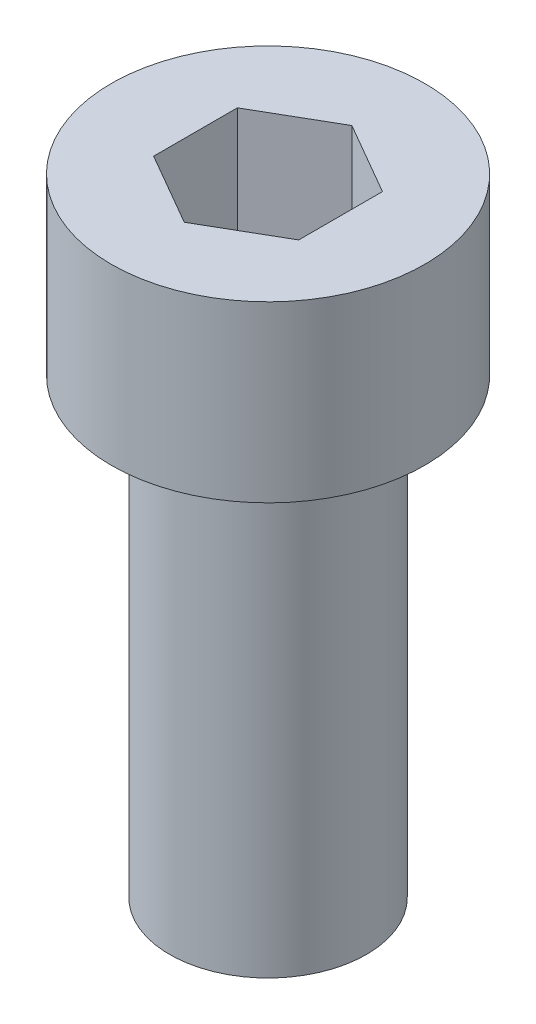
from build123d import *

# Parameters (mm, degrees)
SKETCH1_R           = 2.7
BOSS_EXTRUDE1_DEPTH = 3
SKETCH2_R           = 1.696293742
BOSS_EXTRUDE2_DEPTH = 7.8
CUT_EXTRUDE1_DEPTH  = 2


with BuildPart() as part:
    # Sketch1 → Boss-Extrude1 (new body)
    with BuildSketch(Plane(origin=(0, 0, 0), x_dir=(1, 0, 0), z_dir=(0, 1, 0))):
        with Locations((184.714490272, -125.24429514)):
            Circle(SKETCH1_R)
    extrude(amount=-BOSS_EXTRUDE1_DEPTH)

    # Sketch2 → Boss-Extrude2 (add)
    with BuildSketch(Plane.XZ.offset(3)):
        with Locations((184.714490272, 125.24429514)):
            Circle(SKETCH2_R)
    extrude(amount=BOSS_EXTRUDE2_DEPTH)

    # Sketch3 → Cut-Extrude1 (cut)
    with BuildSketch(Plane(origin=(0, 0, 0), x_dir=(1, 0, 0), z_dir=(0, 1, 0))):
        Polygon((184.714490272, -123.800919467), (183.464490272, -124.522607304), (183.464490272, -125.965982977), (184.714490272, -126.687670813), (185.964490272, -125.965982977), (185.964490272, -124.522607304), align=None)
    extrude(amount=-CUT_EXTRUDE1_DEPTH, mode=Mode.SUBTRACT)


solid = part.part
